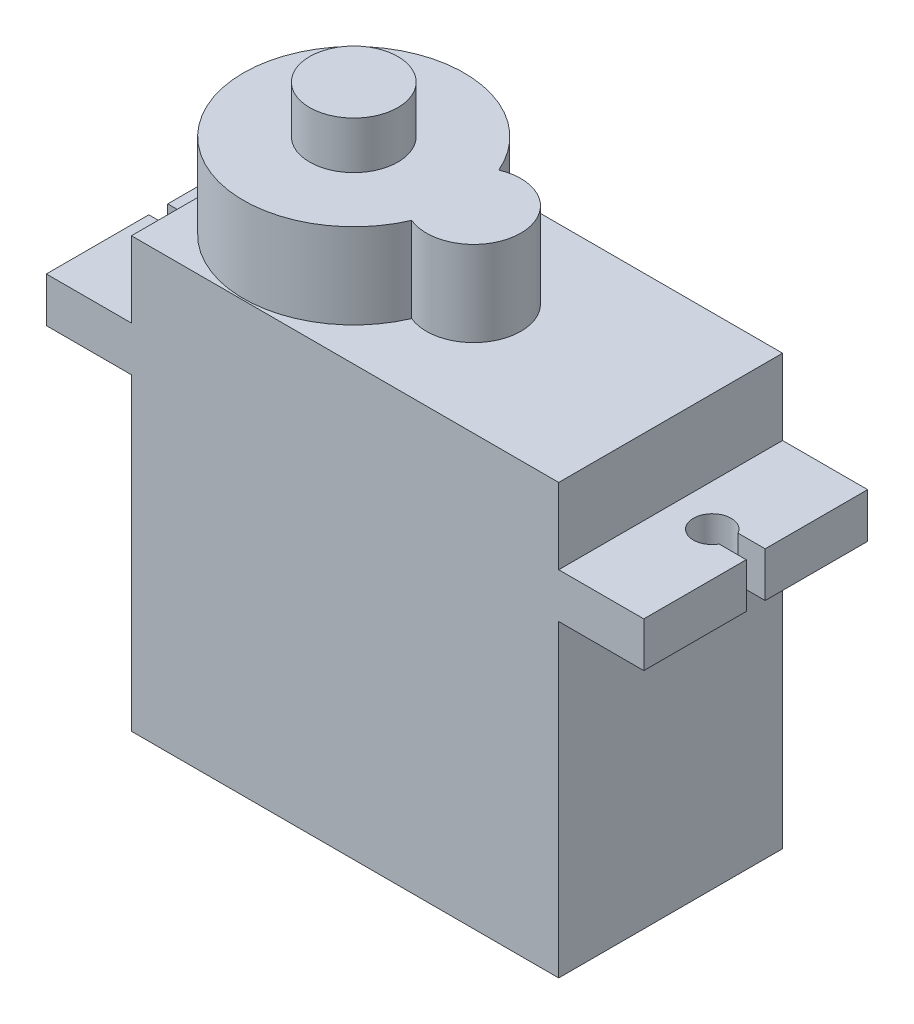
from build123d import *

# Parameters (mm, degrees)
SKETCH1_W            = 22.6
SKETCH1_H            = 11.84
BOSS_EXTRUDE1_DEPTH  = 22.7
SKETCH4_R            = 5.84
BOSS_EXTRUDE6_DEPTH  = 4.5
SKETCH12_R           = 2.335
BOSS_EXTRUDE7_DEPTH  = 2.5
SKETCH13_R           = 2.5
BOSS_EXTRUDE8_DEPTH  = 4.5
SKETCH14_W           = 11.84
SKETCH14_H           = 2.37
BOSS_EXTRUDE10_DEPTH = 4.5
SKETCH15_R           = 1
SKETCH15_W           = 1.5
SKETCH15_H           = 1
CUT_EXTRUDE3_DEPTH   = 19.7
SKETCH16_W           = 11.84
SKETCH16_H           = 2.37
BOSS_EXTRUDE11_DEPTH = 4.5
SKETCH17_R           = 1
SKETCH17_W           = 1.5
SKETCH17_H           = 1
CUT_EXTRUDE4_DEPTH   = 19.7


with BuildPart() as part:
    # Sketch1 → Boss-Extrude1 (new body)
    with BuildSketch(Plane(origin=(0, 0, 0), x_dir=(1, 0, 0), z_dir=(0, 1, 0))):
        with Locations((-34.895532414, -1.336861806)):
            Rectangle(SKETCH1_W, SKETCH1_H)
    extrude(amount=BOSS_EXTRUDE1_DEPTH)

    # Sketch4 → Boss-Extrude6 (add)
    with BuildSketch(Plane(origin=(0, 22.7, 0), x_dir=(-1, 0, 0), z_dir=(0, 1, 0))):
        with Locations((40.355532414, 1.336861806)):
            Circle(SKETCH4_R)
    extrude(amount=BOSS_EXTRUDE6_DEPTH)

    # Sketch12 → Boss-Extrude7 (add)
    with BuildSketch(Plane(origin=(0, 27.2, 0), x_dir=(-1, 0, 0), z_dir=(0, 1, 0))):
        with Locations((40.355532414, 1.336861806)):
            Circle(SKETCH12_R)
    extrude(amount=BOSS_EXTRUDE7_DEPTH)

    # Sketch13 → Boss-Extrude8 (add)
    with BuildSketch(Plane(origin=(0, 22.7, 0), x_dir=(-1, 0, 0), z_dir=(0, 1, 0))):
        with Locations((34.015532414, 1.336861806)):
            Circle(SKETCH13_R)
    extrude(amount=BOSS_EXTRUDE8_DEPTH)

    # Sketch14 → Boss-Extrude10 (add)
    with BuildSketch(Plane(origin=(-23.595532414, 0, 0), x_dir=(0, 0, -1), z_dir=(1, 0, 0))):
        with Locations((-1.336861806, 17.515)):
            Rectangle(SKETCH14_W, SKETCH14_H)
    extrude(amount=BOSS_EXTRUDE10_DEPTH)

    # Sketch15 → Cut-Extrude3 (cut, through all)
    with BuildSketch(Plane(origin=(0, 18.7, 0), x_dir=(-1, 0, 0), z_dir=(0, 1, 0))):
        with Locations((21.395532414, 1.336861806)):
            Circle(SKETCH15_R)
        with Locations((48.395532414, 1.336861806)):
            Circle(SKETCH15_R)
        with Locations((19.845532414, 1.336861806)):
            Rectangle(SKETCH15_W, SKETCH15_H)
    extrude(amount=-CUT_EXTRUDE3_DEPTH, mode=Mode.SUBTRACT)

    # Sketch16 → Boss-Extrude11 (add)
    with BuildSketch(Plane.ZY.offset(46.195532414)):
        with Locations((1.336861806, 17.515)):
            Rectangle(SKETCH16_W, SKETCH16_H)
    extrude(amount=BOSS_EXTRUDE11_DEPTH)

    # Sketch17 → Cut-Extrude4 (cut, through all)
    with BuildSketch(Plane(origin=(0, 18.7, 0), x_dir=(-1, 0, 0), z_dir=(0, 1, 0))):
        with Locations((48.295532414, 1.336861806)):
            Circle(SKETCH17_R)
        with Locations((49.945532414, 1.336861806)):
            Rectangle(SKETCH17_W, SKETCH17_H)
    extrude(amount=-CUT_EXTRUDE4_DEPTH, mode=Mode.SUBTRACT)


solid = part.part
